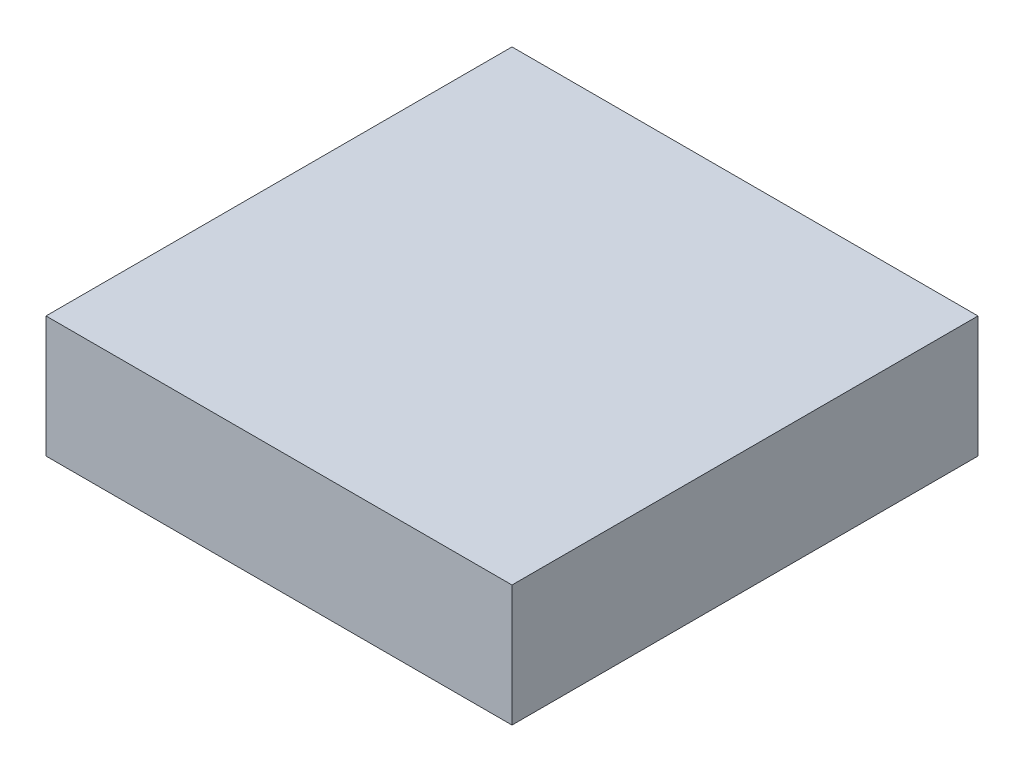
from build123d import *

# Parameters (mm, degrees)
SKETCH1_W           = 96
SKETCH1_H           = 96
BOSS_EXTRUDE1_DEPTH = 12.5


with BuildPart() as part:
    # Sketch1 → Boss-Extrude1 (new body, symmetric)
    with BuildSketch(Plane(origin=(0, 0, 0), x_dir=(1, 0, 0), z_dir=(0, 1, 0))):
        Rectangle(SKETCH1_W, SKETCH1_H)
    extrude(amount=BOSS_EXTRUDE1_DEPTH, both=True)


solid = part.part
